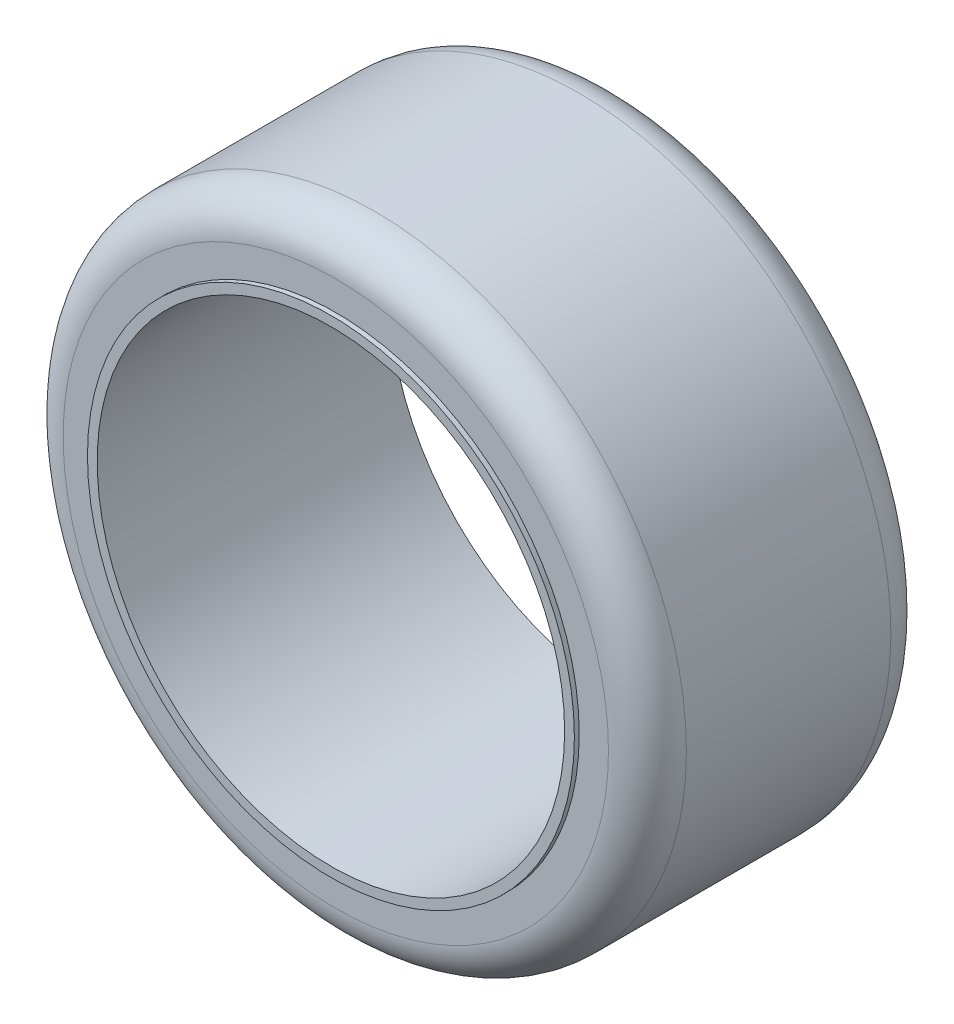
from build123d import *

# Parameters (mm, degrees)
ESQUISSE1_R                     = 25
ESQUISSE1_R_2                   = 24
BOSS_EXTRU_1_DEPTH              = 30
ESQUISSE2_R                     = 32
ESQUISSE2_R_2                   = 25
BOSS_EXTRU_2_DEPTH              = 30
ESQUISSE3_R                     = 35
ESQUISSE3_R_2                   = 25
ENL_V_DE_MAT_EXTRU_MINCE1_DEPTH = 0.5
CONG_1_R                        = 4


with BuildPart() as part:
    # Esquisse1 → Boss.-Extru.1 (new body)
    with BuildSketch(Plane.XY):
        Circle(ESQUISSE1_R)
        Circle(ESQUISSE1_R_2, mode=Mode.SUBTRACT)
    extrude(amount=BOSS_EXTRU_1_DEPTH)

    # Esquisse2 → Boss.-Extru.2 (add)
    with BuildSketch(Plane.XY.offset(30)):
        Circle(ESQUISSE2_R)
        Circle(ESQUISSE2_R_2, mode=Mode.SUBTRACT)
    extrude(amount=-BOSS_EXTRU_2_DEPTH)

    # Esquisse3 → Enlèv. de mat.-Extru.-Mince1 (cut)
    with BuildSketch(Plane.XY.offset(30)):
        Circle(ESQUISSE3_R)
        Circle(ESQUISSE3_R_2, mode=Mode.SUBTRACT)
    enl_v_de_mat_extru_mince1 = extrude(amount=-ENL_V_DE_MAT_EXTRU_MINCE1_DEPTH, mode=Mode.SUBTRACT)

    # Symétrie1: Enlèv. de mat.-Extru.-Mince1 across plane
    add(enl_v_de_mat_extru_mince1.mirror(Plane.XY.offset(15)), mode=Mode.SUBTRACT)

    # Congé1
    cong_1_edges = [part.edges().sort_by_distance(p)[0] for p in [
        (-32, 0, 29.5),
        (-32, 0, 0.5),
    ]]
    fillet(cong_1_edges, radius=CONG_1_R)


solid = part.part
